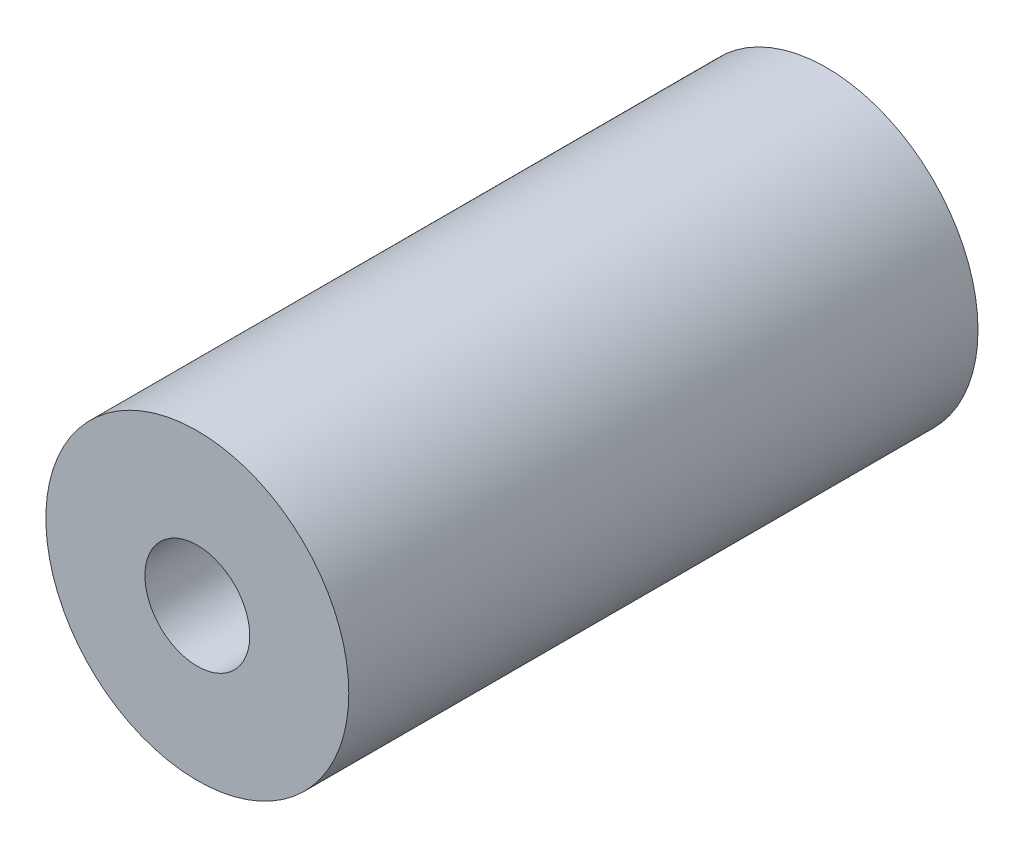
from build123d import *

# Parameters (mm, degrees)
SKETCH1_R           = 13
SKETCH1_R_2         = 4.5
BOSS_EXTRUDE1_DEPTH = 54


with BuildPart() as part:
    # Sketch1 → Boss-Extrude1 (new body)
    with BuildSketch(Plane.XY):
        Circle(SKETCH1_R)
        Circle(SKETCH1_R_2, mode=Mode.SUBTRACT)
    extrude(amount=BOSS_EXTRUDE1_DEPTH)


solid = part.part
